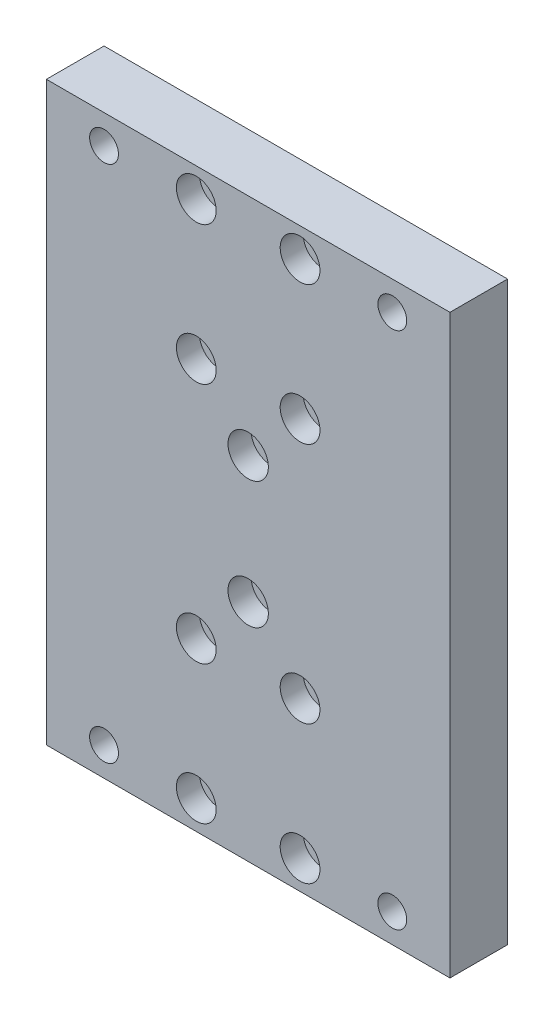
from build123d import *

# Parameters (mm, degrees)
SKETCH1_W           = 70
SKETCH1_H           = 100
BOSS_EXTRUDE1_DEPTH = 10
SKETCH2_R           = 2.5
CUT_EXTRUDE1_DEPTH  = 11
SKETCH3_R           = 1.5
CUT_EXTRUDE2_DEPTH  = 11
SKETCH4_R           = 3.45
CUT_EXTRUDE3_DEPTH  = 4
SKETCH5_R           = 2
CUT_EXTRUDE4_DEPTH  = 11
SKETCH6_R           = 3.5
CUT_EXTRUDE5_DEPTH  = 4


with BuildPart() as part:
    # Sketch1 → Boss-Extrude1 (new body)
    with BuildSketch(Plane.XY):
        Rectangle(SKETCH1_W, SKETCH1_H)
    extrude(amount=BOSS_EXTRUDE1_DEPTH)

    # Sketch2 → Cut-Extrude1 (cut, through all)
    with BuildSketch(Plane(origin=(0, 0, 0), x_dir=(-1, 0, 0), z_dir=(0, 0, -1))):
        with Locations((-25, 45)):
            Circle(SKETCH2_R)
        with Locations((25, 45)):
            Circle(SKETCH2_R)
        with Locations((-25, -45)):
            Circle(SKETCH2_R)
        with Locations((25, -45)):
            Circle(SKETCH2_R)
    extrude(amount=-CUT_EXTRUDE1_DEPTH, mode=Mode.SUBTRACT)

    # Sketch3 → Cut-Extrude2 (cut, through all)
    with BuildSketch(Plane(origin=(0, 0, 0), x_dir=(-1, 0, 0), z_dir=(0, 0, -1))):
        with Locations((9, 21)):
            Circle(SKETCH3_R)
        with Locations((9, 45)):
            Circle(SKETCH3_R)
        with Locations((-9, 21)):
            Circle(SKETCH3_R)
        with Locations((-9, 45)):
            Circle(SKETCH3_R)
        with Locations((9, -45)):
            Circle(SKETCH3_R)
        with Locations((9, -21)):
            Circle(SKETCH3_R)
        with Locations((-9, -45)):
            Circle(SKETCH3_R)
        with Locations((-9, -21)):
            Circle(SKETCH3_R)
    extrude(amount=-CUT_EXTRUDE2_DEPTH, mode=Mode.SUBTRACT)

    # Sketch4 → Cut-Extrude3 (cut)
    with BuildSketch(Plane.XY.offset(10)):
        with Locations((-9, 45)):
            Circle(SKETCH4_R)
        with Locations((-9, 21)):
            Circle(SKETCH4_R)
        with Locations((9, 21)):
            Circle(SKETCH4_R)
        with Locations((9, 45)):
            Circle(SKETCH4_R)
        with Locations((9, -21)):
            Circle(SKETCH4_R)
        with Locations((-9, -21)):
            Circle(SKETCH4_R)
        with Locations((-9, -45)):
            Circle(SKETCH4_R)
        with Locations((9, -45)):
            Circle(SKETCH4_R)
    extrude(amount=-CUT_EXTRUDE3_DEPTH, mode=Mode.SUBTRACT)

    # Sketch5 → Cut-Extrude4 (cut, through all)
    with BuildSketch(Plane.XY.offset(10)):
        with Locations((0, -11)):
            Circle(SKETCH5_R)
        with Locations((0, 11)):
            Circle(SKETCH5_R)
    extrude(amount=-CUT_EXTRUDE4_DEPTH, mode=Mode.SUBTRACT)

    # Sketch6 → Cut-Extrude5 (cut)
    with BuildSketch(Plane.XY.offset(10)):
        with Locations((0, 11)):
            Circle(SKETCH6_R)
        with Locations((0, -11)):
            Circle(SKETCH6_R)
    extrude(amount=-CUT_EXTRUDE5_DEPTH, mode=Mode.SUBTRACT)


solid = part.part
